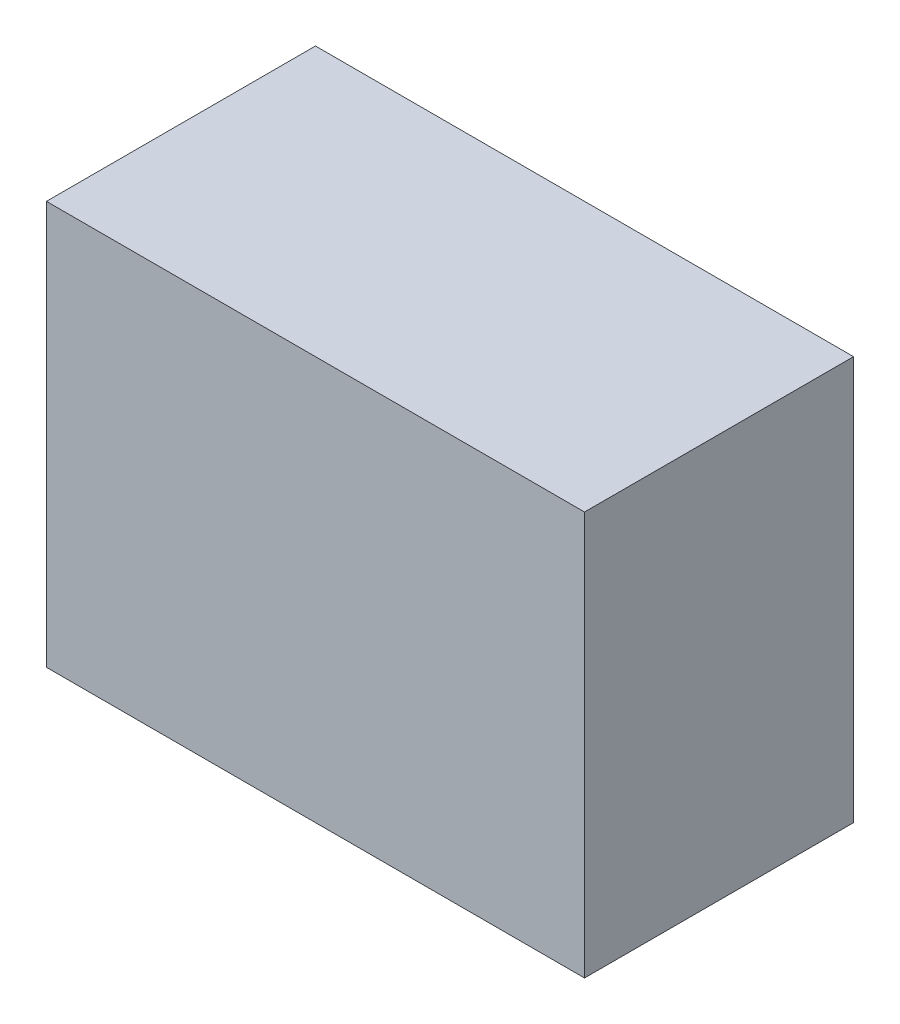
from build123d import *

# Parameters (mm, degrees)
SKETCH1_W           = 40
SKETCH1_H           = 30
BOSS_EXTRUDE1_DEPTH = 20
SKETCH3_R           = 11
CUT_EXTRUDE3_DEPTH  = 7


with BuildPart() as part:
    # Sketch1 → Boss-Extrude1 (new body)
    with BuildSketch(Plane.XY):
        with Locations((20, 15)):
            Rectangle(SKETCH1_W, SKETCH1_H)
    extrude(amount=BOSS_EXTRUDE1_DEPTH)

    # Sketch3 → Cut-Extrude3 (cut)
    with BuildSketch(Plane(origin=(0, 0, 0), x_dir=(-1, 0, 0), z_dir=(0, 0, -1))):
        with Locations((-20, 15)):
            Circle(SKETCH3_R)
    extrude(amount=-CUT_EXTRUDE3_DEPTH, mode=Mode.SUBTRACT)


solid = part.part
